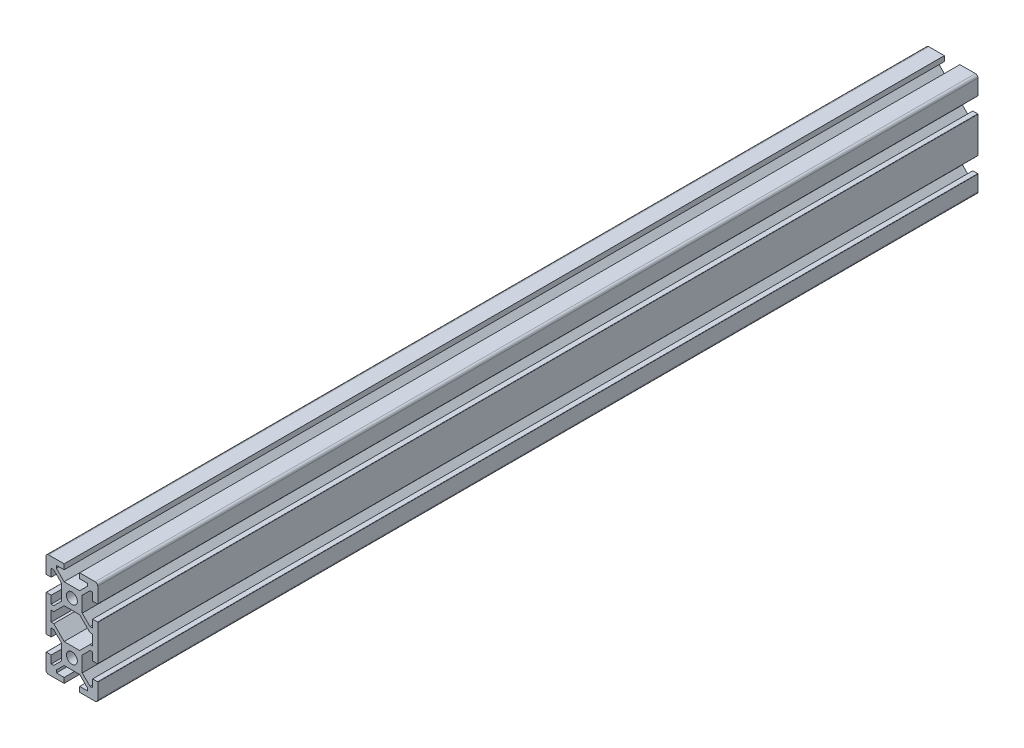
from build123d import *

# Parameters (mm, degrees)
SKETCH1_R           = 2.1
BOSS_EXTRUDE1_DEPTH = 340
FILLET1_R           = 0.1


with BuildPart() as part:
    # Sketch1 → Boss-Extrude1 (new body)
    with BuildSketch(Plane.XY):
        with BuildLine():
            Line((10, -19), (10, -13))
            Line((10, -13), (8, -13))
            Line((8, -13), (8, -16))
            Line((8, -16), (7, -16))
            Line((7, -16), (4, -13))
            Line((4, -13), (4, -7))
            Line((4, -7), (7, -4))
            Line((7, -4), (8, -4))
            Line((8, -4), (8, -7))
            Line((8, -7), (10, -7))
            Line((10, -7), (10, 7))
            Line((10, 7), (8, 7))
            Line((8, 7), (8, 4))
            Line((8, 4), (7, 4))
            Line((7, 4), (4, 7))
            Line((4, 7), (4, 13))
            Line((4, 13), (7, 16))
            Line((7, 16), (8, 16))
            Line((8, 16), (8, 13))
            Line((8, 13), (10, 13))
            Line((10, 13), (10, 19))
            ThreePointArc((10, 19), (9.707106781, 19.707106781), (9, 20))
            Line((9, 20), (3, 20))
            Line((3, 20), (3, 18))
            Line((3, 18), (6, 18))
            Line((6, 18), (6, 17))
            Line((6, 17), (3, 14))
            Line((3, 14), (-3, 14))
            Line((-3, 14), (-6, 17))
            Line((-6, 17), (-6, 18))
            Line((-6, 18), (-3, 18))
            Line((-3, 18), (-3, 20))
            Line((-3, 20), (-9, 20))
            ThreePointArc((-9, 20), (-9.707106781, 19.707106781), (-10, 19))
            Line((-10, 19), (-10, 13))
            Line((-10, 13), (-8, 13))
            Line((-8, 13), (-8, 16))
            Line((-8, 16), (-7, 16))
            Line((-7, 16), (-4, 13))
            Line((-4, 13), (-4, 7))
            Line((-4, 7), (-7, 4))
            Line((-7, 4), (-8, 4))
            Line((-8, 4), (-8, 7))
            Line((-8, 7), (-10, 7))
            Line((-10, 7), (-10, -7))
            Line((-10, -7), (-8, -7))
            Line((-8, -7), (-8, -4))
            Line((-8, -4), (-7, -4))
            Line((-7, -4), (-4, -7))
            Line((-4, -7), (-4, -13))
            Line((-4, -13), (-7, -16))
            Line((-7, -16), (-8, -16))
            Line((-8, -16), (-8, -13))
            Line((-8, -13), (-10, -13))
            Line((-10, -13), (-10, -19))
            ThreePointArc((-10, -19), (-9.707106781, -19.707106781), (-9, -20))
            Line((-9, -20), (-3, -20))
            Line((-3, -20), (-3, -18))
            Line((-3, -18), (-6, -18))
            Line((-6, -18), (-6, -17))
            Line((-6, -17), (-3, -14))
            Line((-3, -14), (3, -14))
            Line((3, -14), (6, -17))
            Line((6, -17), (6, -18))
            Line((6, -18), (3, -18))
            Line((3, -18), (3, -20))
            Line((3, -20), (9, -20))
            ThreePointArc((9, -20), (9.707106781, -19.707106781), (10, -19))
        make_face()
        with Locations((0, -10)):
            Circle(SKETCH1_R, mode=Mode.SUBTRACT)
        with Locations((0, 10)):
            Circle(SKETCH1_R, mode=Mode.SUBTRACT)
        Polygon((-7, -2), (-8, -2), (-8, 2), (-7, 2), (-3, 6), (3, 6), (7, 2), (8, 2), (8, -2), (7, -2), (3, -6), (-3, -6), align=None, mode=Mode.SUBTRACT)
    extrude(amount=-BOSS_EXTRUDE1_DEPTH)

    # Fillet1
    fillet1_edges = [part.edges().sort_by_distance(p)[0] for p in [
        (-10, -13, -170),
        (-10, -7, -170),
        (-10, 7, -170),
        (-10, 13, -170),
        (10, 13, -170),
        (10, 7, -170),
        (10, -7, -170),
        (10, -13, -170),
    ]]
    fillet(fillet1_edges, radius=FILLET1_R)


solid = part.part
